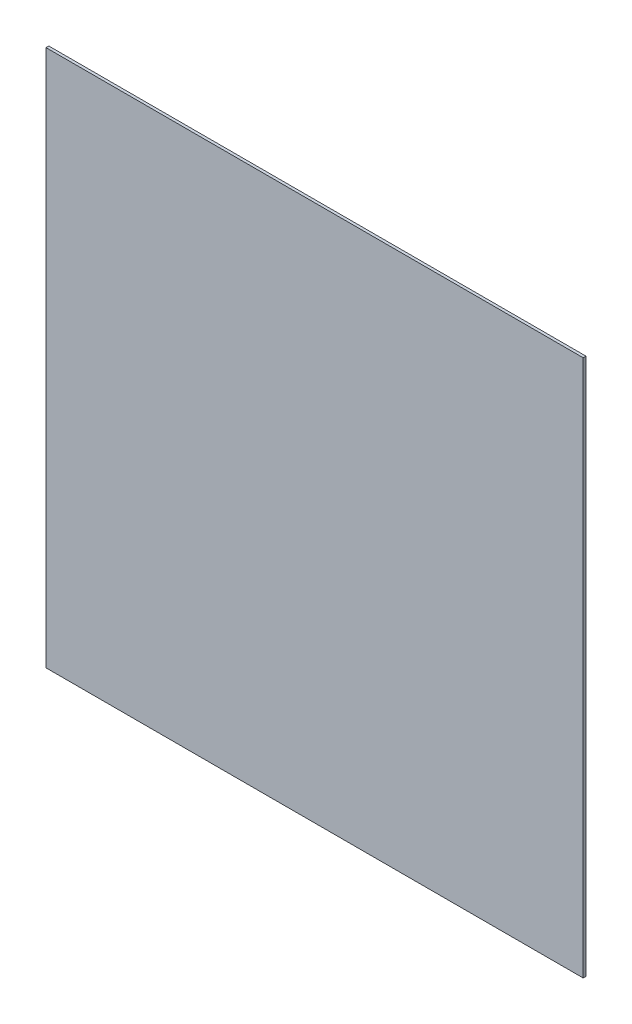
from build123d import *

# Parameters (mm, degrees)
SKETCH1_W           = 609.6
SKETCH1_H           = 609.6
BOSS_EXTRUDE1_DEPTH = 1.5875


with BuildPart() as part:
    # Sketch1 → Boss-Extrude1 (new body, symmetric)
    with BuildSketch(Plane.XY):
        Rectangle(SKETCH1_W, SKETCH1_H)
    extrude(amount=BOSS_EXTRUDE1_DEPTH, both=True)


solid = part.part
